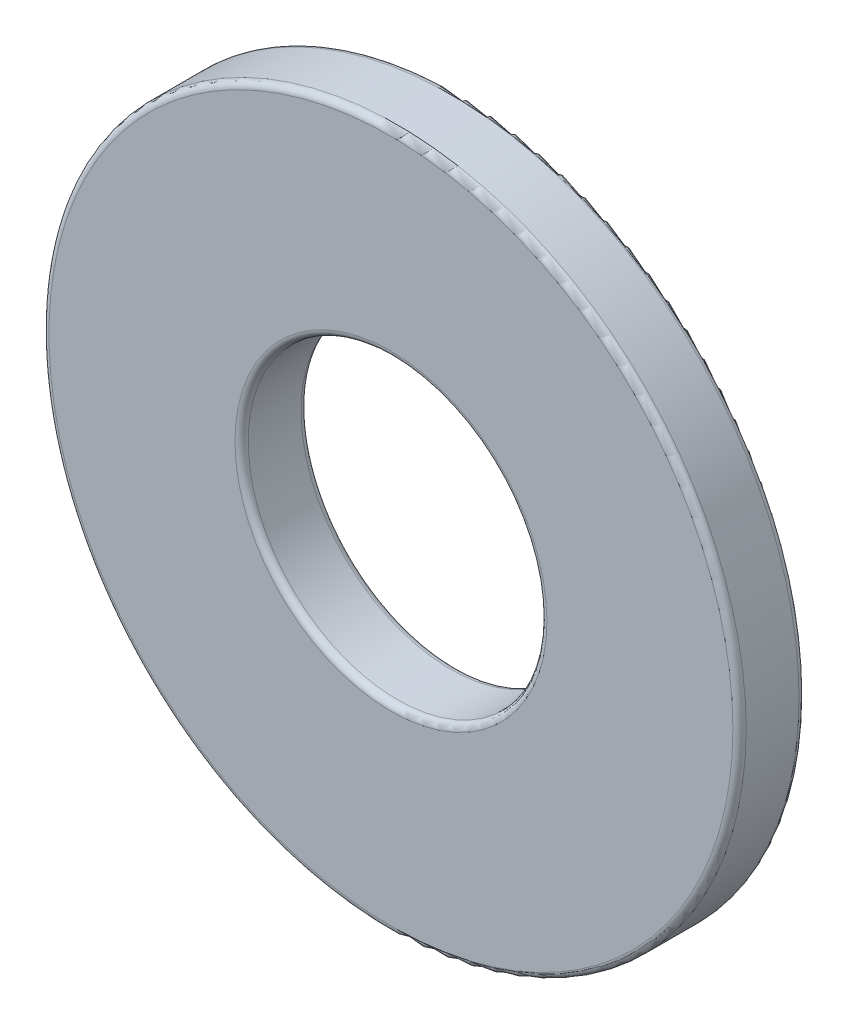
from build123d import *

# Parameters (mm, degrees)
SKETCH3_R                = 11.1125
SKETCH3_R_2              = 4.7625
BOSS_EXTRUDE1_DEPTH      = 1.0541
BOSS_EXTRUDE1_DEPTH_BACK = 1.0541
FILLET1_R                = 0.21082


with BuildPart() as part:
    # Sketch3 → Boss-Extrude1 (new body, two sides)
    with BuildSketch(Plane.XY) as boss_extrude1_sk:
        Circle(SKETCH3_R)
        Circle(SKETCH3_R_2, mode=Mode.SUBTRACT)
    extrude(amount=BOSS_EXTRUDE1_DEPTH)
    extrude(boss_extrude1_sk.sketch, amount=-BOSS_EXTRUDE1_DEPTH_BACK)

    # Fillet1
    fillet1_edges = [part.edges().sort_by_distance(p)[0] for p in [
        (-11.1125, 0, -1.0541),
        (-4.7625, 0, -1.0541),
        (-11.1125, 0, 1.0541),
        (-4.7625, 0, 1.0541),
    ]]
    fillet(fillet1_edges, radius=FILLET1_R)


solid = part.part
